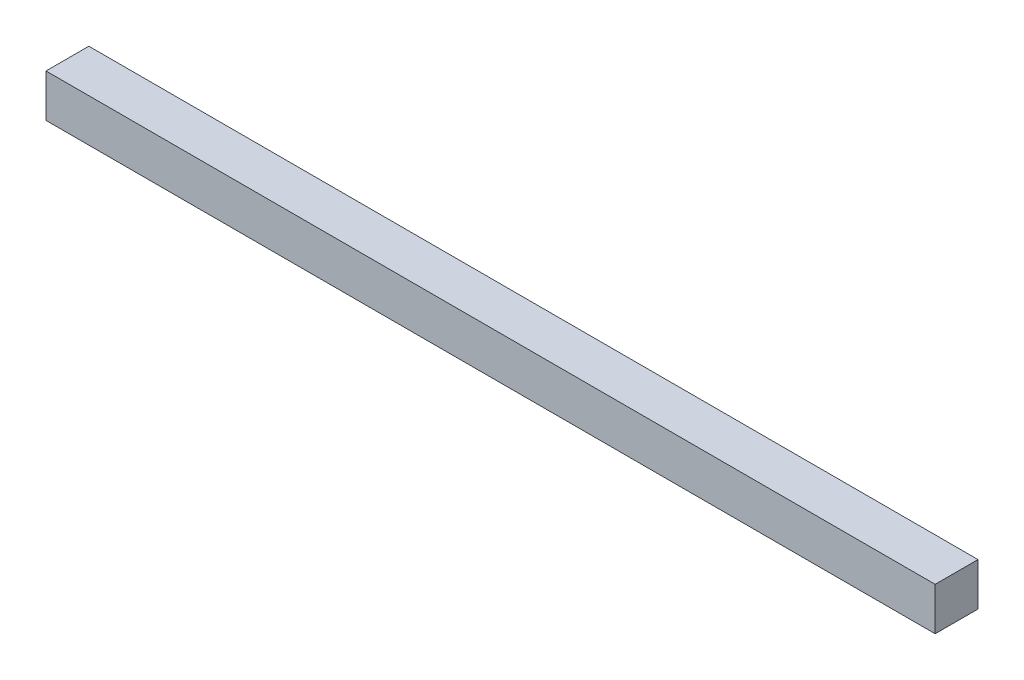
from build123d import *

# Parameters (mm, degrees)
SKETCH1_W           = 103.75
SKETCH1_H           = 5
BOSS_EXTRUDE1_DEPTH = 5


with BuildPart() as part:
    # Sketch1 → Boss-Extrude1 (new body)
    with BuildSketch(Plane(origin=(0, 0, 0), x_dir=(1, 0, 0), z_dir=(0, 1, 0))):
        with Locations((51.875, 2.5)):
            Rectangle(SKETCH1_W, SKETCH1_H)
    extrude(amount=BOSS_EXTRUDE1_DEPTH)


solid = part.part
